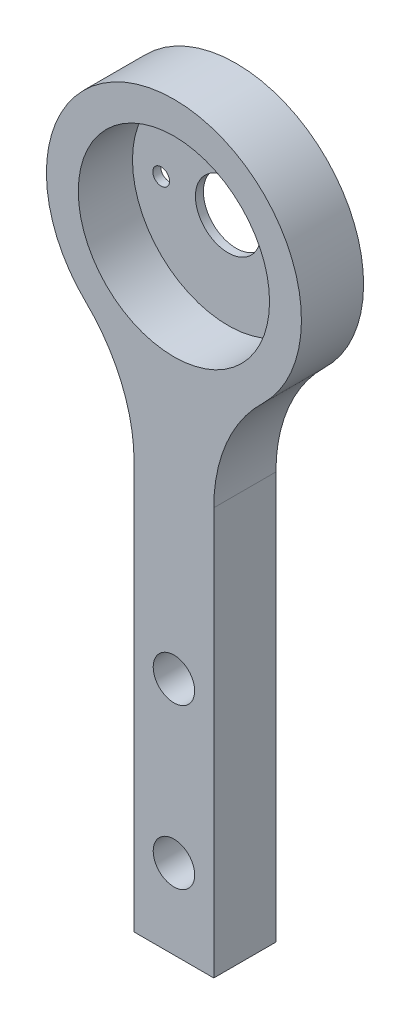
from build123d import *

# Parameters (mm, degrees)
SKETCH1_R                                       = 6
BOSS_EXTRUDE1_DEPTH                             = 3.9
SKETCH5_R                                       = 8
SKETCH5_R_2                                     = 2.05
SKETCH5_R_3                                     = 0.525
BOSS_EXTRUDE3_DEPTH                             = 0.5
CSK_FOR_M2_FLAT_HEAD_MACHINE_SCREW1_D           = 2.6
CSK_FOR_M2_FLAT_HEAD_MACHINE_SCREW1_CSINK_D     = 4.4
CSK_FOR_M2_FLAT_HEAD_MACHINE_SCREW1_CSINK_ANGLE = 90


with BuildPart() as part:
    # Sketch1 → Boss-Extrude1 (new body)
    with BuildSketch(Plane.XY):
        with BuildLine():
            Line((-2.5, -12.951833847), (-2.5, -38.5))
            Line((-2.5, -38.5), (2.5, -38.5))
            Line((2.5, -38.5), (2.5, -12.951833847))
            ThreePointArc((2.5, -12.951833847), (3.295532486, -9.043154047), (5.555555556, -5.756370599))
            ThreePointArc((5.555555556, -5.756370599), (0, 8), (-5.555555556, -5.756370599))
            ThreePointArc((-5.555555556, -5.756370599), (-3.295532486, -9.043154047), (-2.5, -12.951833847))
        make_face()
        Circle(SKETCH1_R, mode=Mode.SUBTRACT)
    extrude(amount=BOSS_EXTRUDE1_DEPTH)

    # Sketch5 → Boss-Extrude3 (add)
    with BuildSketch(Plane(origin=(0, 0, 0), x_dir=(-1, 0, 0), z_dir=(0, 0, -1))):
        Circle(SKETCH5_R)
        Circle(SKETCH5_R_2, mode=Mode.SUBTRACT)
        with Locations((4.2, 0)):
            Circle(SKETCH5_R_3, mode=Mode.SUBTRACT)
        with Locations((-4.2, 0)):
            Circle(SKETCH5_R_3, mode=Mode.SUBTRACT)
    extrude(amount=-BOSS_EXTRUDE3_DEPTH)

    # CSK for M2 Flat Head Machine Screw1 (through all)
    with Locations(Plane(origin=(0, 0, 0), x_dir=(-1, 0, 0), z_dir=(0, 0, -1))):
        with Locations((0, -33.5), (0, -23.5)):
            CounterSinkHole(CSK_FOR_M2_FLAT_HEAD_MACHINE_SCREW1_D / 2, CSK_FOR_M2_FLAT_HEAD_MACHINE_SCREW1_CSINK_D / 2, counter_sink_angle=CSK_FOR_M2_FLAT_HEAD_MACHINE_SCREW1_CSINK_ANGLE)


solid = part.part
